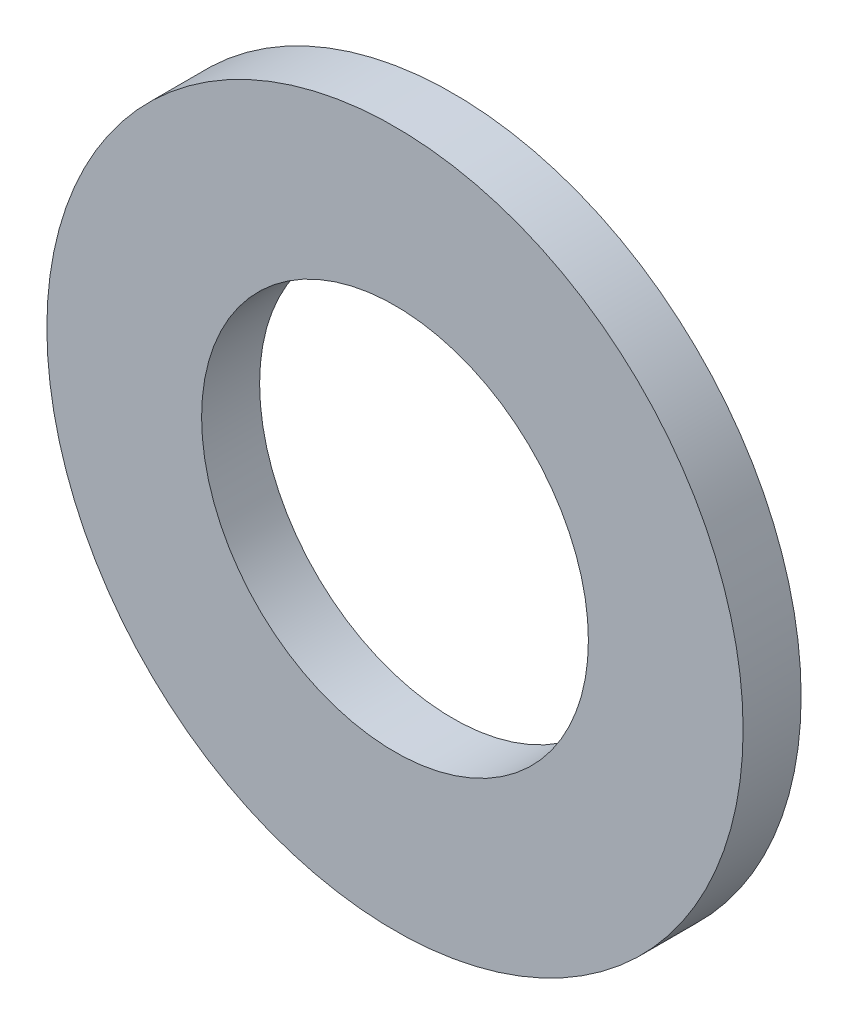
from build123d import *

# Parameters (mm, degrees)
SKETCH5_R                = 9
SKETCH5_R_2              = 5
BOSS_EXTRUDE1_DEPTH      = 0.75
BOSS_EXTRUDE1_DEPTH_BACK = 0.75


with BuildPart() as part:
    # Sketch5 → Boss-Extrude1 (new body, two sides)
    with BuildSketch(Plane.XY) as boss_extrude1_sk:
        Circle(SKETCH5_R)
        Circle(SKETCH5_R_2, mode=Mode.SUBTRACT)
    extrude(amount=BOSS_EXTRUDE1_DEPTH)
    extrude(boss_extrude1_sk.sketch, amount=-BOSS_EXTRUDE1_DEPTH_BACK)


solid = part.part
